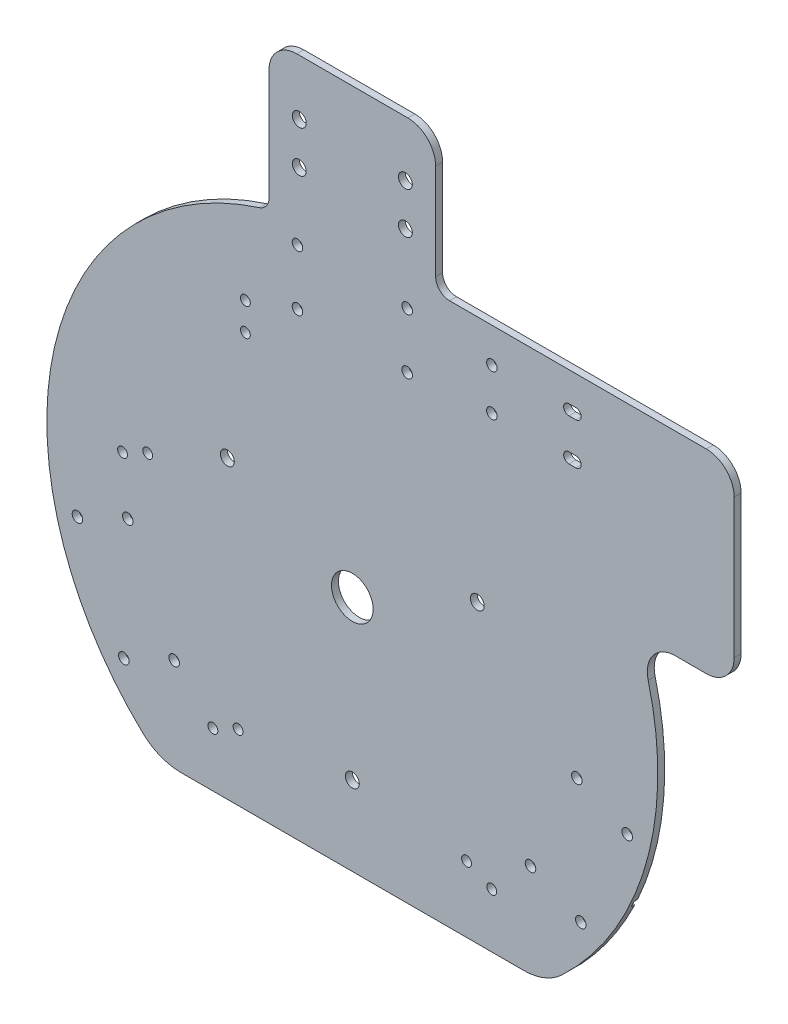
from build123d import *

# Parameters (mm, degrees)
BOSS_EXTRUDE1_DEPTH = 3.175
CUT_EXTRUDE3_DEPTH  = 1.5875
SKETCH3_R           = 9.525
CUT_EXTRUDE4_DEPTH  = 4.175
CUT_EXTRUDE5_DEPTH  = 4.175
SKETCH8_R           = 2.413
CUT_EXTRUDE7_DEPTH  = 4.175
SKETCH9_R           = 2.413
CUT_EXTRUDE8_DEPTH  = 4.175
FILLET1_R           = 12.7
CUT_EXTRUDE9_DEPTH  = 4.175
FILLET2_R           = 25.4
SKETCH11_R          = 2.2479
CUT_EXTRUDE10_DEPTH = 4.175
SKETCH14_R          = 3.175
BOSS_EXTRUDE2_DEPTH = 3.175
FILLET3_R           = 12.7
FILLET4_R           = 6.35


with BuildPart() as part:
    # Sketch1 → Boss-Extrude1 (new body)
    with BuildSketch(Plane.XY):
        with BuildLine():
            Line((0, 139.7), (139.7, 139.7))
            Line((139.7, 139.7), (174.625, 139.7))
            Line((174.625, 139.7), (174.625, 50.700684167))
            Line((174.625, 50.700684167), (130.175, 50.700684167))
            ThreePointArc((130.175, 50.700684167), (-78.845432404, -115.323405209), (0, 139.7))
        make_face()
    extrude(amount=BOSS_EXTRUDE1_DEPTH)

    # Sketch2 → Cut-Extrude3 (cut)
    with BuildSketch(Plane(origin=(0, 0, 0), x_dir=(-1, 0, 0), z_dir=(0, 0, -1))):
        Polygon((-1.5875, -1.011349039), (-1.5875, -2.491875854), (0, -1.751612446), align=None)
        Polygon((-1.5875, -1.011349039), (0, -1.751612446), (1.5875, -1.011349039), (1.5875, 1.011349039), (0, 1.751612446), (-1.5875, 1.011349039), align=None)
        Polygon((1.5875, -1.011349039), (0, -1.751612446), (1.5875, -2.491875854), align=None)
        Polygon((-3.756345013, 0), (-1.5875, -1.011349039), (-1.5875, 1.011349039), align=None)
        Polygon((-1.5875, 2.491875854), (-1.5875, 1.011349039), (0, 1.751612446), align=None)
        Polygon((0, 1.751612446), (1.5875, 1.011349039), (1.5875, 2.491875854), align=None)
        Polygon((1.5875, 1.011349039), (1.5875, -1.011349039), (3.756345013, 0), align=None)
        with BuildLine():
            ThreePointArc((-127.273929282, -57.597195461), (-126.611197849, -59.039771165), (-125.932116301, -60.474722685))
            Line((-125.932116301, -60.474722685), (-120.185236911, -57.794908815))
            Line((-120.185236911, -57.794908815), (-121.527049892, -54.917381591))
            Line((-121.527049892, -54.917381591), (-127.273929282, -57.597195461))
        make_face()
        with BuildLine():
            Line((121.527049892, 54.917381591), (127.273929282, 57.597195461))
            ThreePointArc((127.273929282, 57.597195461), (126.611197849, 59.039771165), (125.932116301, 60.474722685))
            Line((125.932116301, 60.474722685), (120.185236911, 57.794908815))
            Line((120.185236911, 57.794908815), (121.527049892, 54.917381591))
        make_face()
        with BuildLine():
            Line((120.185236911, -57.794908815), (125.932116301, -60.474722685))
            ThreePointArc((125.932116301, -60.474722685), (126.611197849, -59.039771165), (127.273929282, -57.597195461))
            Line((127.273929282, -57.597195461), (121.527049892, -54.917381591))
            Line((121.527049892, -54.917381591), (120.185236911, -57.794908815))
        make_face()
        with BuildLine():
            Line((0, 139.7), (-1.5875, 139.7))
            Line((-1.5875, 139.7), (-1.5875, 133.35))
            Line((-1.5875, 133.35), (1.5875, 133.35))
            Line((1.5875, 133.35), (1.5875, 139.690979822))
            ThreePointArc((1.5875, 139.690979822), (0.793762813, 139.697744937), (0, 139.7))
        make_face()
    extrude(amount=-CUT_EXTRUDE3_DEPTH, mode=Mode.SUBTRACT)

    # Sketch3 → Cut-Extrude4 (cut, through all)
    with BuildSketch(Plane.XY.offset(3.175)):
        Circle(SKETCH3_R)
    extrude(amount=-CUT_EXTRUDE4_DEPTH, mode=Mode.SUBTRACT)

    # Sketch2_4 → Cut-Extrude5 (cut, through all)
    with BuildSketch(Plane(origin=(0, 0, 0), x_dir=(-1, 0, 0), z_dir=(0, 0, -1))):
        with BuildLine():
            Line((-60.312918166, 26.37276318), (-55.328894815, 24.048674923))
            ThreePointArc((-55.328894815, 24.048674923), (-54.333740605, 25.183430817), (-53.975, 26.649482664))
            ThreePointArc((-53.975, 26.649482664), (-53.978021896, 26.787974218), (-53.987081834, 26.926202147))
            Line((-53.987081834, 26.926202147), (-58.971105185, 29.250290404))
            ThreePointArc((-58.971105185, 29.250290404), (-60.027527224, 27.991295645), (-60.312918166, 26.37276318))
        make_face()
        with BuildLine():
            ThreePointArc((-60.312918166, 26.37276318), (-58.491812981, 23.77195544), (-55.328894815, 24.048674923))
            Line((-55.328894815, 24.048674923), (-60.312918166, 26.37276318))
        make_face()
        with BuildLine():
            Line((-58.971105185, 29.250290404), (-53.987081834, 26.926202147))
            ThreePointArc((-53.987081834, 26.926202147), (-55.808187019, 29.527009887), (-58.971105185, 29.250290404))
        make_face()
        with BuildLine():
            ThreePointArc((53.987081834, 26.926202147), (54.272472776, 25.307669683), (55.328894815, 24.048674923))
            Line((55.328894815, 24.048674923), (60.312918166, 26.37276318))
            ThreePointArc((60.312918166, 26.37276318), (60.321978104, 26.510991109), (60.325, 26.649482664))
            ThreePointArc((60.325, 26.649482664), (59.966259395, 28.115534511), (58.971105185, 29.250290404))
            Line((58.971105185, 29.250290404), (53.987081834, 26.926202147))
        make_face()
        with BuildLine():
            ThreePointArc((58.971105185, 29.250290404), (55.808187019, 29.527009887), (53.987081834, 26.926202147))
            Line((53.987081834, 26.926202147), (58.971105185, 29.250290404))
        make_face()
        with BuildLine():
            Line((60.312918166, 26.37276318), (55.328894815, 24.048674923))
            ThreePointArc((55.328894815, 24.048674923), (58.491812981, 23.77195544), (60.312918166, 26.37276318))
        make_face()
        with BuildLine():
            ThreePointArc((-1.5875, -69.587590332), (-3.175, -72.337220989), (-1.5875, -75.086851646))
            Line((-1.5875, -75.086851646), (-1.5875, -69.587590332))
        make_face()
        with BuildLine():
            Line((-1.5875, -69.587590332), (-1.5875, -75.086851646))
            ThreePointArc((-1.5875, -75.086851646), (0, -75.512220989), (1.5875, -75.086851646))
            Line((1.5875, -75.086851646), (1.5875, -69.587590332))
            ThreePointArc((1.5875, -69.587590332), (0, -69.162220989), (-1.5875, -69.587590332))
        make_face()
        with BuildLine():
            Line((1.5875, -69.587590332), (1.5875, -75.086851646))
            ThreePointArc((1.5875, -75.086851646), (2.749630657, -73.924720989), (3.175, -72.337220989))
            ThreePointArc((3.175, -72.337220989), (2.749630657, -70.749720989), (1.5875, -69.587590332))
        make_face()
    extrude(amount=-CUT_EXTRUDE5_DEPTH, mode=Mode.SUBTRACT)

    # Sketch8 → Cut-Extrude7 (cut, through all)
    with BuildSketch(Plane.XY.offset(3.175)):
        with Locations((25.0825, 101.6)):
            Circle(SKETCH8_R)
        with Locations((-25.0825, 101.6)):
            Circle(SKETCH8_R)
        with Locations((-25.0825, 127)):
            Circle(SKETCH8_R)
        with Locations((25.0825, 127)):
            Circle(SKETCH8_R)
        with Locations((102.681193713, -20.205550325)):
            Circle(SKETCH8_R)
        with Locations((125.701411504, -30.940054173)):
            Circle(SKETCH8_R)
        with Locations((81.480548613, -65.670480461)):
            Circle(SKETCH8_R)
        with Locations((104.500766404, -76.404984309)):
            Circle(SKETCH8_R)
        with Locations((-81.480548613, -65.670480461)):
            Circle(SKETCH8_R)
        with Locations((-104.500766404, -76.404984309)):
            Circle(SKETCH8_R)
        with Locations((-102.681193713, -20.205550325)):
            Circle(SKETCH8_R)
        with Locations((-125.701411504, -30.940054173)):
            Circle(SKETCH8_R)
    extrude(amount=-CUT_EXTRUDE7_DEPTH, mode=Mode.SUBTRACT)

    # Sketch9 → Cut-Extrude8 (cut, through all)
    with BuildSketch(Plane.XY.offset(3.175)):
        with Locations((100.6475, 123.825)):
            Circle(SKETCH9_R)
        with Locations((63.8175, 123.825)):
            Circle(SKETCH9_R)
        with Locations((63.8175, 104.775)):
            Circle(SKETCH9_R)
        with Locations((100.6475, 104.775)):
            Circle(SKETCH9_R)
        with BuildLine():
            Line((99.06, 121.412), (100.6475, 121.412))
            ThreePointArc((100.6475, 121.412), (98.2345, 123.825000007), (100.647500013, 126.238))
            Line((100.647500013, 126.238), (99.06, 126.238))
            ThreePointArc((99.06, 126.238), (96.647, 123.825), (99.06, 121.412))
        make_face()
        with BuildLine():
            Line((100.6475, 121.412), (102.235, 121.412))
            ThreePointArc((102.235, 121.412), (104.648, 123.825), (102.235, 126.238))
            Line((102.235, 126.238), (100.647500013, 126.238))
            ThreePointArc((100.647500013, 126.238), (102.353748668, 125.531248658), (103.0605, 123.825))
            ThreePointArc((103.0605, 123.825), (102.353748663, 122.118751337), (100.6475, 121.412))
        make_face()
        with BuildLine():
            ThreePointArc((100.6475, 102.362), (98.2345, 104.775), (100.6475, 107.188))
            Line((100.6475, 107.188), (99.06, 107.188))
            ThreePointArc((99.06, 107.188), (96.647, 104.775), (99.06, 102.362))
            Line((99.06, 102.362), (100.6475, 102.362))
        make_face()
        with BuildLine():
            ThreePointArc((102.235, 102.362), (104.648, 104.775), (102.235, 107.188))
            Line((102.235, 107.188), (100.6475, 107.188))
            ThreePointArc((100.6475, 107.188), (102.353748663, 106.481248663), (103.0605, 104.775))
            ThreePointArc((103.0605, 104.775), (102.353748663, 103.068751337), (100.6475, 102.362))
            Line((100.6475, 102.362), (102.235, 102.362))
        make_face()
    extrude(amount=-CUT_EXTRUDE8_DEPTH, mode=Mode.SUBTRACT)

    # Fillet1
    fillet1_edges = [part.edges().sort_by_distance(p)[0] for p in [
        (174.625, 139.7, 1.5875),
        (174.625, 50.700684167, 1.5875),
        (130.175, 50.700684167, 1.5875),
    ]]
    fillet(fillet1_edges, radius=FILLET1_R)

    # Sketch10 → Cut-Extrude9 (cut, through all)
    with BuildSketch(Plane.XY.offset(3.175)):
        with BuildLine():
            Line((87.894185103, -108.585), (-87.894185103, -108.585))
            ThreePointArc((-87.894185103, -108.585), (0, -139.7), (87.894185103, -108.585))
        make_face()
    extrude(amount=-CUT_EXTRUDE9_DEPTH, mode=Mode.SUBTRACT)

    # Fillet2
    fillet2_edges = [part.edges().sort_by_distance(p)[0] for p in [
        (-87.894185103, -108.585, 1.5875),
        (87.894185103, -108.585, 1.5875),
    ]]
    fillet(fillet2_edges, radius=FILLET2_R)

    # Sketch11 → Cut-Extrude10 (cut, through all)
    with BuildSketch(Plane.XY.offset(3.175)):
        with Locations((-93.58045976, 10.312378308)):
            Circle(SKETCH11_R)
        with Locations((-105.090568655, 4.945126384)):
            Circle(SKETCH11_R)
        with Locations((-52.252619944, -78.315460186)):
            Circle(SKETCH11_R)
        with Locations((-63.76272884, -83.68271211)):
            Circle(SKETCH11_R)
        with Locations((52.252619944, -78.315460186)):
            Circle(SKETCH11_R)
        with Locations((63.76272884, -83.68271211)):
            Circle(SKETCH11_R)
        with Locations((-48.895, 93.1545)):
            Circle(SKETCH11_R)
        with Locations((-48.895, 80.4545)):
            Circle(SKETCH11_R)
    extrude(amount=-CUT_EXTRUDE10_DEPTH, mode=Mode.SUBTRACT)

    # Sketch14 → Boss-Extrude2 (add)
    with BuildSketch(Plane(origin=(0, 0, 0), x_dir=(-1, 0, 0), z_dir=(0, 0, -1))):
        with BuildLine():
            Line((-38.1, 139.7), (-38.1, 202.565))
            Line((-38.1, 202.565), (38.1, 202.565))
            Line((38.1, 202.565), (38.1, 134.404166602))
            ThreePointArc((38.1, 134.404166602), (19.233147502, 138.369707802), (0, 139.7))
            Line((0, 139.7), (-38.1, 139.7))
        make_face()
        with Locations((-24.257, 177.165)):
            Circle(SKETCH14_R, mode=Mode.SUBTRACT)
        with Locations((24.257, 177.165)):
            Circle(SKETCH14_R, mode=Mode.SUBTRACT)
        with Locations((24.257, 158.115)):
            Circle(SKETCH14_R, mode=Mode.SUBTRACT)
        with Locations((-24.257, 158.115)):
            Circle(SKETCH14_R, mode=Mode.SUBTRACT)
    extrude(amount=-BOSS_EXTRUDE2_DEPTH)

    # Fillet3
    fillet3_edges = [part.edges().sort_by_distance(p)[0] for p in [
        (38.1, 202.565, 1.5875),
        (-38.1, 202.565, 1.5875),
    ]]
    fillet(fillet3_edges, radius=FILLET3_R)

    # Fillet4
    fillet4_edges = [part.edges().sort_by_distance(p)[0] for p in [
        (-38.1, 134.404166602, 1.5875),
        (38.1, 139.7, 1.5875),
    ]]
    fillet(fillet4_edges, radius=FILLET4_R)


solid = part.part
